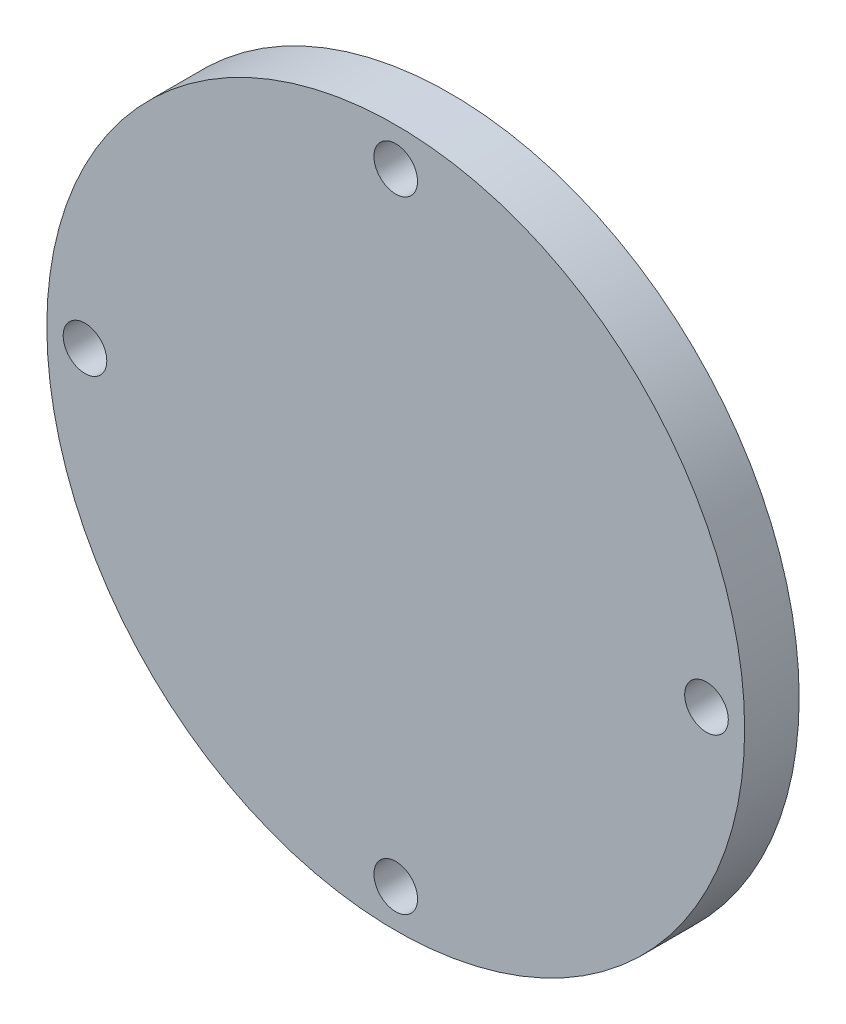
from build123d import *

# Parameters (mm, degrees)
SKETCH1_R           = 32
SKETCH1_R_2         = 2
BOSS_EXTRUDE1_DEPTH = 5


with BuildPart() as part:
    # Sketch1 → Boss-Extrude1 (new body)
    with BuildSketch(Plane.XY):
        Circle(SKETCH1_R)
        with Locations((0, 28.5)):
            Circle(SKETCH1_R_2, mode=Mode.SUBTRACT)
        with Locations((28.5, 0)):
            Circle(SKETCH1_R_2, mode=Mode.SUBTRACT)
        with Locations((0, -28.5)):
            Circle(SKETCH1_R_2, mode=Mode.SUBTRACT)
        with Locations((-28.5, 0)):
            Circle(SKETCH1_R_2, mode=Mode.SUBTRACT)
    extrude(amount=BOSS_EXTRUDE1_DEPTH)


solid = part.part
